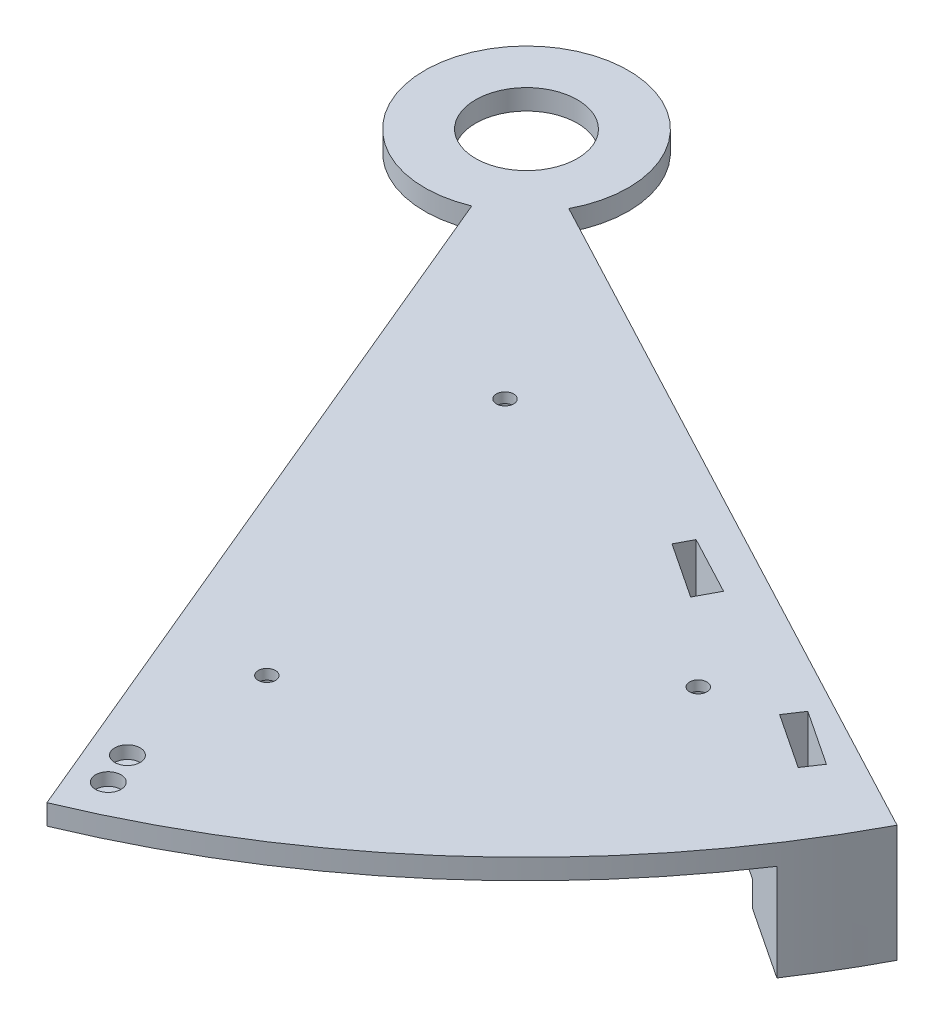
from build123d import *

# Parameters (mm, degrees)
EXTRUDE_2_DEPTH     = 4
SKETCH_2_R          = 2.5
CUT_EXTRUDE_1_DEPTH = 2.5
SKETCH_3_R          = 0.75
CUT_EXTRUDE_2_DEPTH = 5
SKETCH_4_R          = 10
CUT_EXTRUDE_3_DEPTH = 5
EXTRUDE_5_DEPTH     = 19
SKETCH_7_R          = 1.7
CUT_EXTRUDE_4_DEPTH = 10
SKETCH_8_R          = 3
CUT_EXTRUDE_5_DEPTH = 2
CUT_EXTRUDE_6_DEPTH = 24
CUT_EXTRUDE_7_DEPTH = 5
CUT_EXTRUDE_8_DEPTH = 5
CUT_EXTRUDE_9_DEPTH = 24


with BuildPart() as part:
    # Sketch 1 → Extrude 2 (new body)
    with BuildSketch(Plane(origin=(0, 0, 0), x_dir=(1, 0, 0), z_dir=(0, 1, 0))):
        with BuildLine():
            Line((67.500002573, -161.729132047), (7.703281321, -18.456962288))
            ThreePointArc((7.703281321, -18.456962288), (-13.478048898, 14.776406799), (17.672702948, -9.363523402))
            Line((17.672702948, -9.363523402), (154.857059584, -82.047873812))
            ThreePointArc((154.857059584, -82.047873812), (118.101403468, -129.478264581), (67.500002573, -161.729132047))
        make_face()
    extrude(amount=EXTRUDE_2_DEPTH)

    # Sketch 2 → Cut-Extrude 1 (cut)
    with BuildSketch(Plane(origin=(0, 4, 0), x_dir=(1, 0, 0), z_dir=(0, 1, 0))):
        with Locations((70.025207674, -152.204211145)):
            Circle(SKETCH_2_R)
        with Locations((67.327175776, -145.739984225)):
            Circle(SKETCH_2_R)
    extrude(amount=-CUT_EXTRUDE_1_DEPTH, mode=Mode.SUBTRACT)

    # Sketch 3 → Cut-Extrude 2 (cut, through all)
    with BuildSketch(Plane(origin=(0, 4, 0), x_dir=(1, 0, 0), z_dir=(0, 1, 0))):
        with Locations((70.025207674, -152.204211145)):
            Circle(SKETCH_3_R)
        with Locations((67.327175776, -145.739984225)):
            Circle(SKETCH_3_R)
    extrude(amount=-CUT_EXTRUDE_2_DEPTH, mode=Mode.SUBTRACT)

    # Sketch 4 → Cut-Extrude 3 (cut, through all)
    with BuildSketch(Plane(origin=(0, 4, 0), x_dir=(1, 0, 0), z_dir=(0, 1, 0))):
        Circle(SKETCH_4_R)
    extrude(amount=-CUT_EXTRUDE_3_DEPTH, mode=Mode.SUBTRACT)

    # Sketch 6 → Extrude 5 (add)
    with BuildSketch(Plane.XZ):
        with BuildLine():
            ThreePointArc((16.66785969, 11.053617207), (17.191063517, 10.220926336), (17.672702948, 9.363523402))
            Line((17.672702948, 9.363523402), (154.857059584, 82.047873812))
            ThreePointArc((154.857059584, 82.047873812), (150.636694066, 89.560867018), (146.05212053, 96.857320781))
            Line((146.05212053, 96.857320781), (16.66785969, 11.053617207))
        make_face()
    extrude(amount=EXTRUDE_5_DEPTH)

    # Sketch 7 → Cut-Extrude 4 (cut)
    with BuildSketch(Plane.XZ):
        with Locations((43.803658918, 48.023322098)):
            Circle(SKETCH_7_R)
        with Locations((111.793635371, 78.04603187)):
            Circle(SKETCH_7_R)
        with Locations((67.464414972, 118.480178564)):
            Circle(SKETCH_7_R)
    extrude(amount=-CUT_EXTRUDE_4_DEPTH, mode=Mode.SUBTRACT)

    # Sketch 8 → Cut-Extrude 5 (cut)
    with BuildSketch(Plane.XZ):
        with Locations((111.793635371, 78.04603187)):
            Circle(SKETCH_8_R)
        with Locations((43.803658918, 48.023322098)):
            Circle(SKETCH_8_R)
        with Locations((67.464414972, 118.480178564)):
            Circle(SKETCH_8_R)
    extrude(amount=-CUT_EXTRUDE_5_DEPTH, mode=Mode.SUBTRACT)

    # Sketch 9 → Cut-Extrude 6 (cut, through all)
    with BuildSketch(Plane.XZ.offset(19)):
        Polygon((95.759242986, 63.504615216), (84.872522382, 56.284873482), (86.511138977, 53.192150466), (97.998395894, 59.278440678), (96.359779298, 62.371163694), align=None)
    extrude(amount=-CUT_EXTRUDE_6_DEPTH, mode=Mode.SUBTRACT)

    # Sketch 9_3 → Cut-Extrude 7 (cut)
    with BuildSketch(Plane.XZ.offset(19)):
        Polygon((97.998395894, 59.278440678), (86.511138977, 53.192150466), (89.554284083, 47.448522008), (101.041540999, 53.53481222), align=None)
    extrude(amount=-CUT_EXTRUDE_7_DEPTH, mode=Mode.SUBTRACT)

    # Sketch 10 → Cut-Extrude 8 (cut)
    with BuildSketch(Plane.XZ.offset(19)):
        Polygon((131.739790556, 87.365819183), (120.905681758, 80.180967998), (124.49810735, 74.763913599), (135.332216149, 81.948764784), align=None)
    extrude(amount=-CUT_EXTRUDE_8_DEPTH, mode=Mode.SUBTRACT)

    # Sketch 10_3 → Cut-Extrude 9 (cut, through all)
    with BuildSketch(Plane.XZ.offset(19)):
        Polygon((124.49810735, 74.763913599), (126.708830792, 71.430341661), (137.54293959, 78.615192846), (135.332216149, 81.948764784), align=None)
    extrude(amount=-CUT_EXTRUDE_9_DEPTH, mode=Mode.SUBTRACT)


solid = part.part
